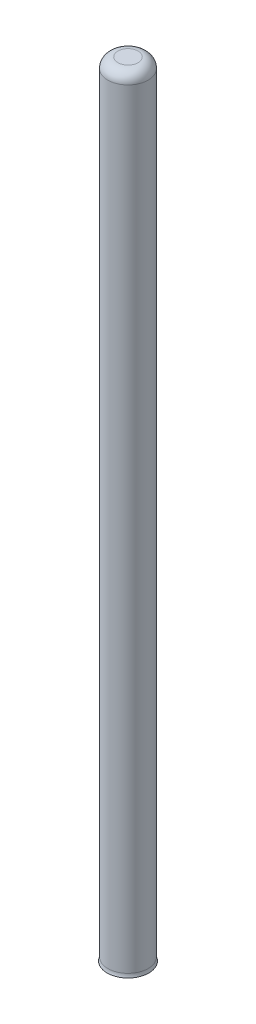
from build123d import *

# Parameters (mm, degrees)
CROQUIS1_R              = 4
SALIENTE_EXTRUIR1_DEPTH = 165
CORTAR_EXTRUIR1_DEPTH   = 7
CROQUIS6_R              = 7.5
CROQUIS6_R_2            = 4
SALIENTE_EXTRUIR2_DEPTH = 8
REDONDEO1_R             = 2
REDONDEO2_R             = 2
CROQUIS9_R              = 9.503185827
CORTAR_EXTRUIR2_DEPTH   = 9.8


with BuildPart() as part:
    # Croquis1 → Saliente-Extruir1 (new body)
    with BuildSketch(Plane(origin=(0, 0, 0), x_dir=(1, 0, 0), z_dir=(0, 1, 0))):
        Circle(CROQUIS1_R)
    extrude(amount=SALIENTE_EXTRUIR1_DEPTH)

    # Croquis2 → Cortar-Extruir1 (cut)
    with BuildSketch(Plane.XZ):
        with BuildLine():
            Line((1.326334604, -2.119159389), (-2.405766703, -0.679916591))
            ThreePointArc((-2.405766703, -0.679916591), (-2.367069949, -0.804350581), (-2.321941863, -0.926599149))
            Line((-2.321941863, -0.926599149), (1.098585485, -2.245686962))
            ThreePointArc((1.098585485, -2.245686962), (1.214109413, -2.185392032), (1.326334604, -2.119159389))
        make_face()
        with BuildLine():
            ThreePointArc((2.321941863, 0.926599149), (2.367069949, 0.804350581), (2.405766703, 0.679916591))
            ThreePointArc((2.405766703, 0.679916591), (2.476329618, 0.34320784), (2.5, 0))
            ThreePointArc((2.5, 0), (2.186988399, -1.211231499), (1.326334604, -2.119159389))
            ThreePointArc((1.326334604, -2.119159389), (1.214109413, -2.185392032), (1.098585485, -2.245686962))
            Line((1.098585485, -2.245686962), (1.254372464, -2.305764455))
            Line((1.254372464, -2.305764455), (1.345452247, -2.340888346))
            ThreePointArc((1.345452247, -2.340888346), (2.336955398, -1.352271964), (2.7, 0))
            ThreePointArc((2.7, 0), (2.667000496, 0.420842435), (2.568808626, 0.831397765))
            Line((2.568808626, 0.831397765), (2.477728843, 0.866521656))
            Line((2.477728843, 0.866521656), (2.321941863, 0.926599149))
        make_face()
        with BuildLine():
            Line((-1.326334604, 2.119159389), (2.405766703, 0.679916591))
            ThreePointArc((2.405766703, 0.679916591), (2.367069949, 0.804350581), (2.321941863, 0.926599149))
            Line((2.321941863, 0.926599149), (-1.098585485, 2.245686962))
            ThreePointArc((-1.098585485, 2.245686962), (-1.214109413, 2.185392032), (-1.326334604, 2.119159389))
        make_face()
        with BuildLine():
            ThreePointArc((-2.405766703, -0.679916591), (-2.332563317, 0.899526749), (-1.326334604, 2.119159389))
            ThreePointArc((-1.326334604, 2.119159389), (-1.214109413, 2.185392032), (-1.098585485, 2.245686962))
            Line((-1.098585485, 2.245686962), (-1.254372464, 2.305764455))
            Line((-1.254372464, 2.305764455), (-1.345452247, 2.340888346))
            ThreePointArc((-1.345452247, 2.340888346), (-2.519168382, 0.971488889), (-2.568808626, -0.831397765))
            Line((-2.568808626, -0.831397765), (-2.477728843, -0.866521656))
            Line((-2.477728843, -0.866521656), (-2.321941863, -0.926599149))
            ThreePointArc((-2.321941863, -0.926599149), (-2.367069949, -0.804350581), (-2.405766703, -0.679916591))
        make_face()
        with BuildLine():
            ThreePointArc((2.5, 0), (2.476329618, 0.34320784), (2.405766703, 0.679916591))
            Line((2.405766703, 0.679916591), (-1.326334604, 2.119159389))
            ThreePointArc((-1.326334604, 2.119159389), (-2.332563317, 0.899526749), (-2.405766703, -0.679916591))
            Line((-2.405766703, -0.679916591), (1.326334604, -2.119159389))
            ThreePointArc((1.326334604, -2.119159389), (2.186988399, -1.211231499), (2.5, 0))
        make_face()
    extrude(amount=-CORTAR_EXTRUIR1_DEPTH, mode=Mode.SUBTRACT)

    # Croquis6 → Saliente-Extruir2 (add)
    with BuildSketch(Plane.XZ):
        Circle(CROQUIS6_R)
        Circle(CROQUIS6_R_2, mode=Mode.SUBTRACT)
    extrude(amount=-SALIENTE_EXTRUIR2_DEPTH)

    # Croquis8 → Revolución1 (revolve)
    with BuildSketch(Plane.XY):
        Polygon((-7.5, 8), (-4, 8), (-4, 9), align=None)
    revolve(axis=Axis((0, 0, 0), (0, 1, 0)))

    # Redondeo1
    redondeo1_edges = [part.edges().sort_by_distance(p)[0] for p in [
        (-7.5, 0, 0),
        (0, 8, -7.5),
    ]]
    fillet(redondeo1_edges, radius=REDONDEO1_R)

    # Redondeo2
    redondeo2_edges = [part.edges().sort_by_distance(p)[0] for p in [
        (0, 9, -4),
        (-4, 165, 0),
    ]]
    fillet(redondeo2_edges, radius=REDONDEO2_R)

    # Croquis9 → Cortar-Extruir2 (cut)
    with BuildSketch(Plane.XZ):
        Circle(CROQUIS9_R)
    extrude(amount=-CORTAR_EXTRUIR2_DEPTH, mode=Mode.SUBTRACT)


solid = part.part
